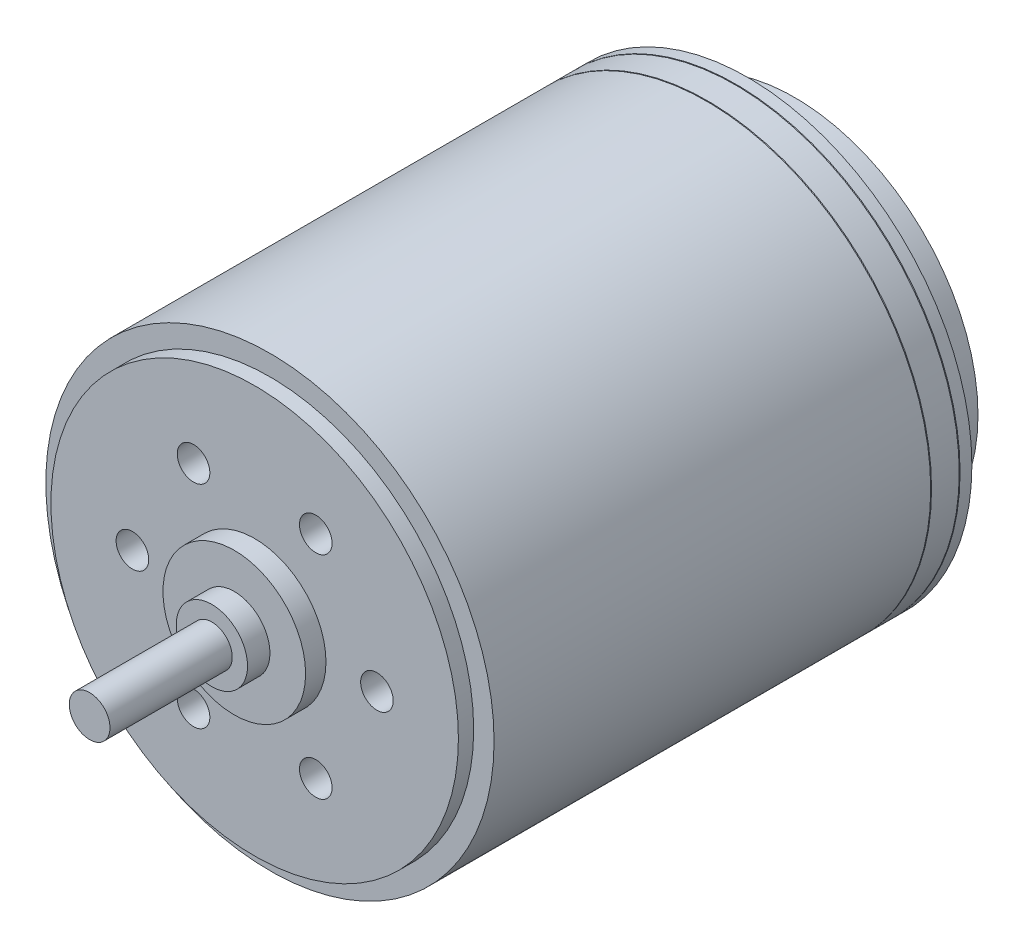
from build123d import *

# Parameters (mm, degrees)
BOSS_EXTRUDE3_DEPTH            = 1
SKETCH7_R                      = 10
BOSS_EXTRUDE4_DEPTH            = 0.75
SKETCH8_R                      = 3.5
BOSS_EXTRUDE5_DEPTH            = 1
SKETCH9_R                      = 1.75
BOSS_EXTRUDE6_DEPTH            = 1.1
SKETCH10_R                     = 1
BOSS_EXTRUDE7_DEPTH            = 6
F_1_6_1_6_DIAMETER_HOLE1_D     = 1.6
F_1_6_1_6_DIAMETER_HOLE1_DEPTH = 4.5
F_1_6_1_6_DIAMETER_HOLE1_TIP   = 0.480688495
SKETCH13_R                     = 9
BOSS_EXTRUDE8_DEPTH            = 2.3


with BuildPart() as part:
    # Sketch1 → Revolve1 (revolve)
    with BuildSketch(Plane(origin=(0, 0, 0), x_dir=(1, 0, 0), z_dir=(0, 1, 0))):
        Polygon((11, 0), (0, 0), (0, -23.45), (11, -23.45), (11, -2.020710678), (10.95, -2), (11, -1.979289322), (11, -0.620710678), (10.95, -0.6), (11, -0.579289322), align=None)
    revolve(axis=Axis((0, 0, 0), (0, 0, 1)))

    # Sketch6 → Boss-Extrude3 (add)
    with BuildSketch(Plane(origin=(0, 0, 0), x_dir=(-1, 0, 0), z_dir=(0, 0, -1))):
        with BuildLine():
            Line((5.05, 5.477225575), (5.05, -5.477225575))
            ThreePointArc((5.05, -5.477225575), (0, -7.45), (-5.05, -5.477225575))
            Line((-5.05, -5.477225575), (-5.05, 5.477225575))
            ThreePointArc((-5.05, 5.477225575), (0, 7.45), (5.05, 5.477225575))
        make_face()
    extrude(amount=BOSS_EXTRUDE3_DEPTH)

    # Sketch7 → Boss-Extrude4 (add)
    with BuildSketch(Plane.XY.offset(23.45)):
        Circle(SKETCH7_R)
    extrude(amount=BOSS_EXTRUDE4_DEPTH)

    # Sketch8 → Boss-Extrude5 (add)
    with BuildSketch(Plane.XY.offset(24.2)):
        Circle(SKETCH8_R)
    extrude(amount=BOSS_EXTRUDE5_DEPTH)

    # Sketch9 → Boss-Extrude6 (add)
    with BuildSketch(Plane.XY.offset(25.2)):
        Circle(SKETCH9_R)
    extrude(amount=BOSS_EXTRUDE6_DEPTH)

    # Sketch10 → Boss-Extrude7 (add)
    with BuildSketch(Plane.XY.offset(26.3)):
        Circle(SKETCH10_R)
    extrude(amount=BOSS_EXTRUDE7_DEPTH)

    # Ø1.6 (1.6) Diameter Hole1
    with Locations(Plane.XY.offset(24.2)):
        with Locations((-3, 5.196152423), (3, 5.196152423), (6, 0), (3, -5.196152423), (-3, -5.196152423), (-6, 0)):
            Hole(F_1_6_1_6_DIAMETER_HOLE1_D / 2, depth=F_1_6_1_6_DIAMETER_HOLE1_DEPTH)
            with Locations((0, 0, -(F_1_6_1_6_DIAMETER_HOLE1_DEPTH + F_1_6_1_6_DIAMETER_HOLE1_TIP / 2))):  # 118° drill point
                Cone(0, F_1_6_1_6_DIAMETER_HOLE1_D / 2, F_1_6_1_6_DIAMETER_HOLE1_TIP, mode=Mode.SUBTRACT)

    # Sketch13 → Boss-Extrude8 (add)
    with BuildSketch(Plane(origin=(0, 0, 0), x_dir=(-1, 0, 0), z_dir=(0, 0, -1))):
        Circle(SKETCH13_R)
    extrude(amount=BOSS_EXTRUDE8_DEPTH)


solid = part.part
